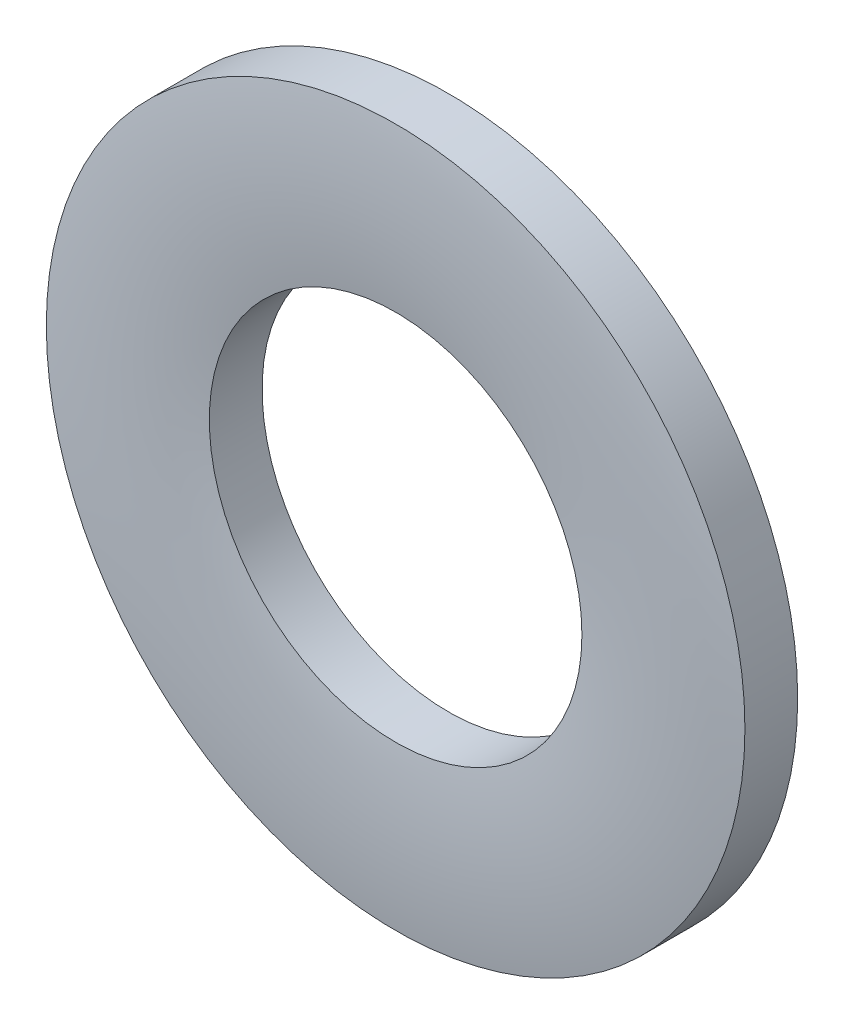
from build123d import *


with BuildPart() as part:
    # Sketch3 → Revolve1 (revolve)
    with BuildSketch(Plane(origin=(0, 0, 0), x_dir=(0, 0, -1), z_dir=(1, 0, 0))):
        with BuildLine():
            Line((0.25, 3), (-0.20315, 3))
            ThreePointArc((-0.20315, 3), (-0.25, 2.3), (-0.20315, 1.6))
            Line((-0.20315, 1.6), (0.25, 1.6))
            Line((0.25, 1.6), (0.25, 3))
        make_face()
    revolve(axis=Axis((0, 0, 0.25), (0, 0, -1)))


solid = part.part
